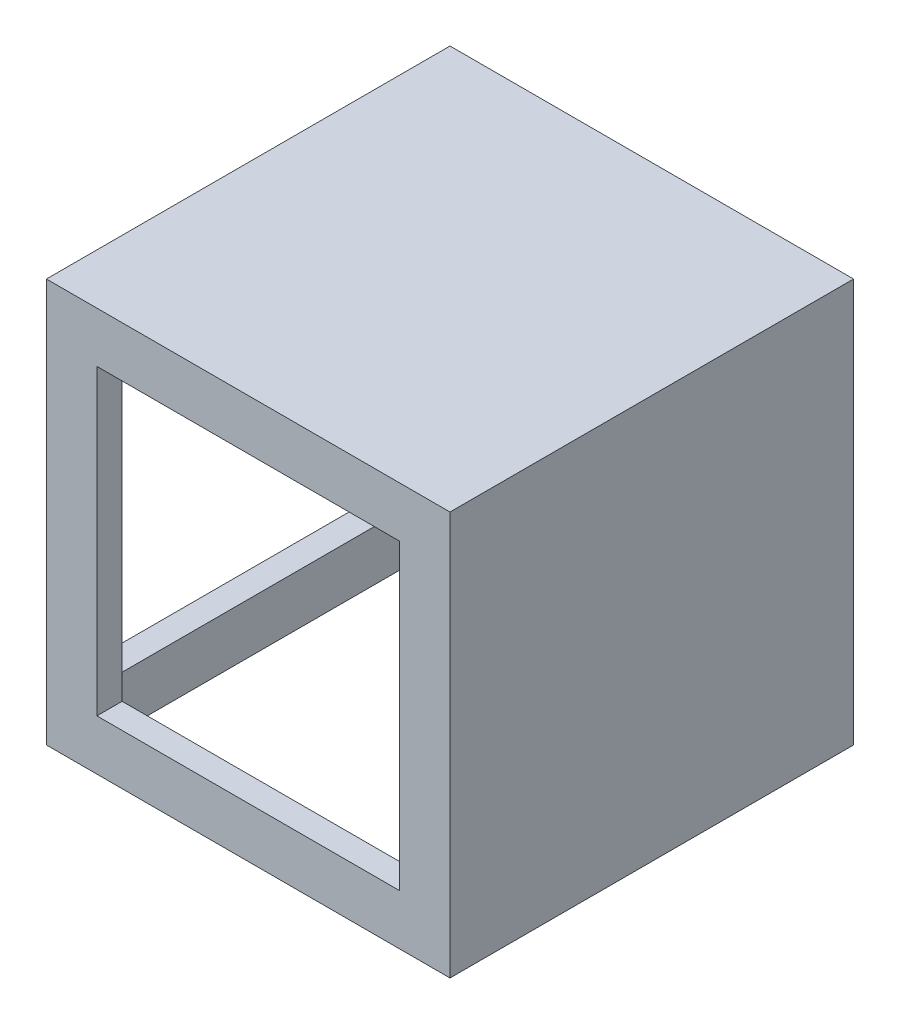
from build123d import *

# Parameters (mm, degrees)
SKETCH1_W           = 16
SKETCH1_H           = 16
BOSS_EXTRUDE1_DEPTH = 16
SHELL1_T            = -1
SKETCH2_W           = 12
SKETCH2_H           = 12
CUT_EXTRUDE1_DEPTH  = 17
SKETCH3_W           = 12
SKETCH3_H           = 12
CUT_EXTRUDE3_DEPTH  = 7


with BuildPart() as part:
    # Sketch1 → Boss-Extrude1 (new body)
    with BuildSketch(Plane.XY):
        with Locations((8, 8)):
            Rectangle(SKETCH1_W, SKETCH1_H)
    extrude(amount=BOSS_EXTRUDE1_DEPTH)

    # Shell1
    shell1_openings = [part.faces().sort_by_distance(p)[0] for p in [
        (8, 0, 8),
    ]]
    offset(amount=SHELL1_T, openings=shell1_openings, kind=Kind.INTERSECTION)

    # Sketch2 → Cut-Extrude1 (cut, through all)
    with BuildSketch(Plane(origin=(0, 0, 0), x_dir=(-1, 0, 0), z_dir=(0, 0, -1))):
        with Locations((-8, 8)):
            Rectangle(SKETCH2_W, SKETCH2_H)
    extrude(amount=-CUT_EXTRUDE1_DEPTH, mode=Mode.SUBTRACT)

    # Sketch3 → Cut-Extrude3 (cut)
    with BuildSketch(Plane.ZY):
        with Locations((8, 8)):
            Rectangle(SKETCH3_W, SKETCH3_H)
    extrude(amount=-CUT_EXTRUDE3_DEPTH, mode=Mode.SUBTRACT)


solid = part.part
